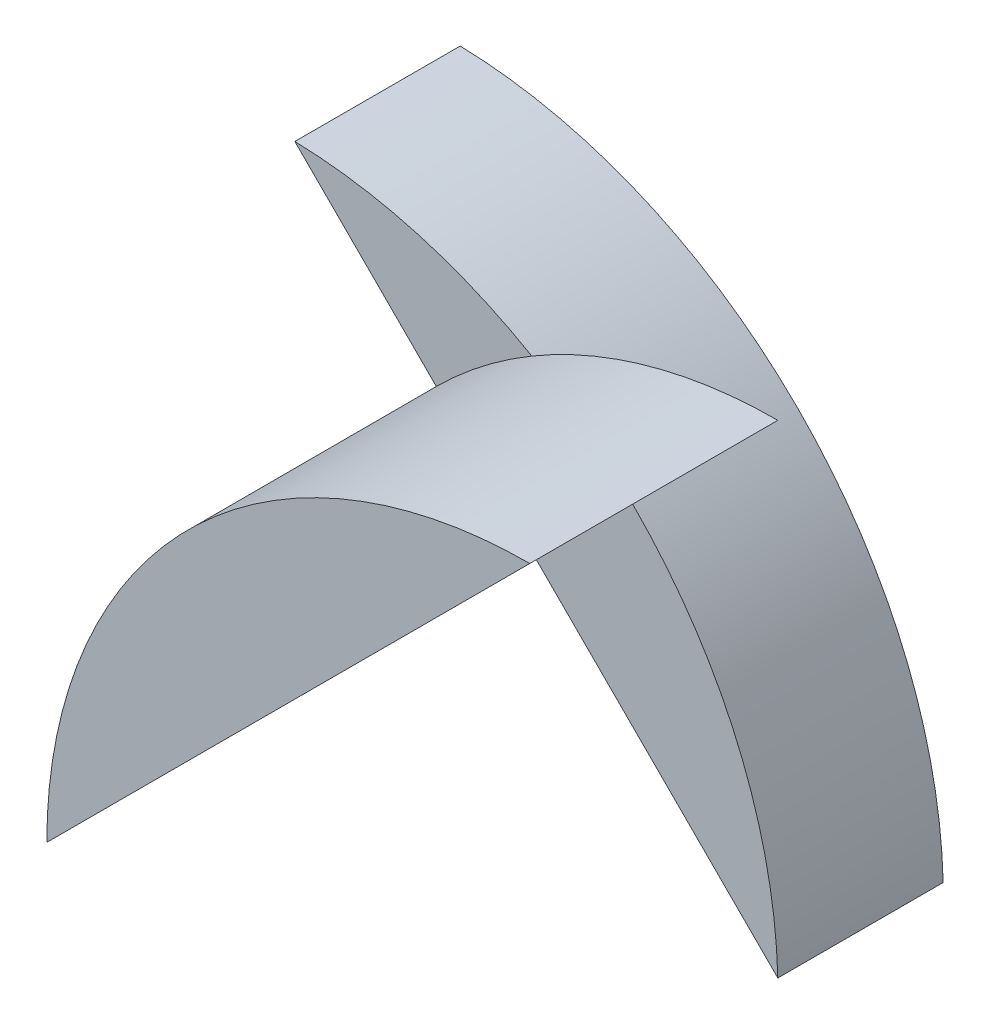
from build123d import *

# Parameters (mm, degrees)
BOSS_EXTRUDE1_DEPTH = 10
BOSS_EXTRUDE2_DEPTH = 15


with BuildPart() as part:
    # Sketch1 → Boss-Extrude1 (new body)
    with BuildSketch(Plane.XY):
        with BuildLine():
            Line((-74.025675485, 30.818815331), (-44.815154686, 1.608294532))
            ThreePointArc((-44.815154686, 1.608294532), (-53.594607127, 22.03936289), (-74.025675485, 30.818815331))
        make_face()
    extrude(amount=BOSS_EXTRUDE1_DEPTH)

    # Sketch3 → Boss-Extrude2 (add)
    with BuildSketch(Plane.XY.offset(10)):
        with BuildLine():
            Line((-74.025675485, 1.608294532), (-44.815154686, 30.818815331))
            ThreePointArc((-44.815154686, 30.818815331), (-65.470112025, 22.263251871), (-74.025675485, 1.608294532))
        make_face()
    extrude(amount=BOSS_EXTRUDE2_DEPTH)


solid = part.part
